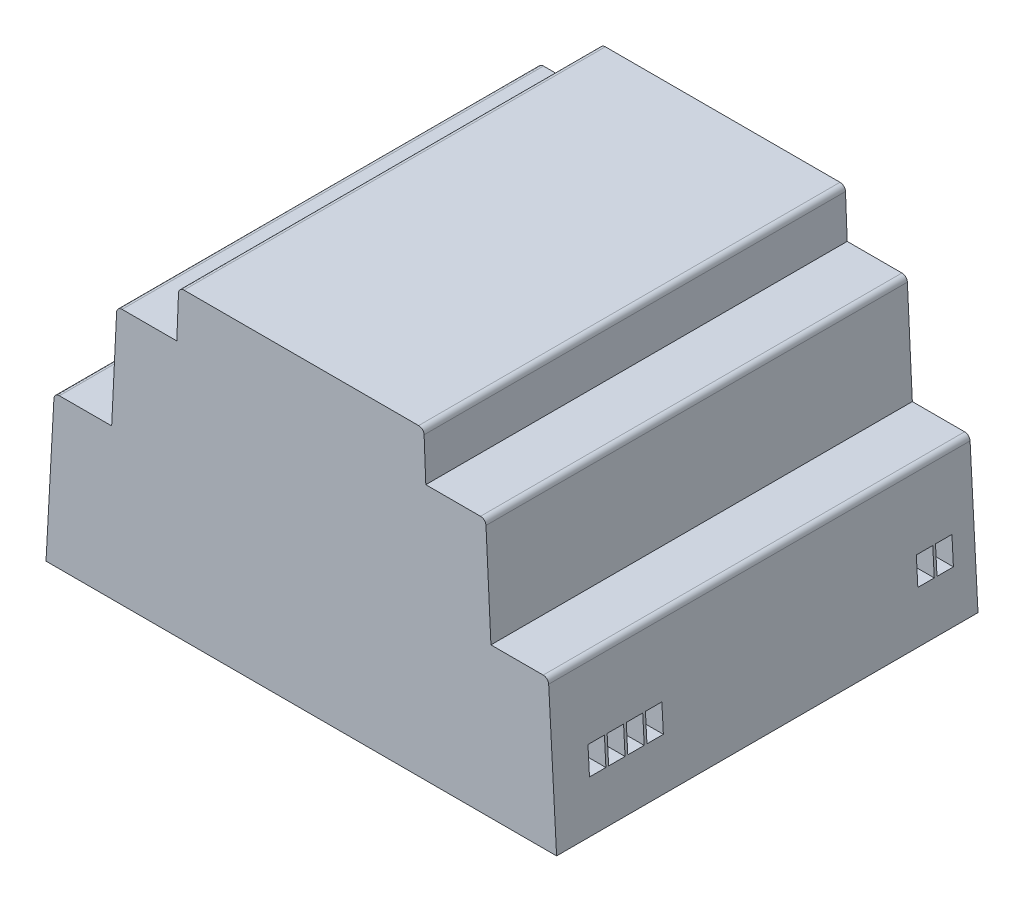
from build123d import *

# Parameters (mm, degrees)
BOSS_EXTRUDE1_DEPTH       = 77
FILLET1_R                 = 1
SKETCH2_W                 = 3
SKETCH2_H                 = 5
CUT_EXTRUDE1_DEPTH        = 10
LPATTERN1_COUNT           = 2
LPATTERN1_PITCH           = 3.5
LPATTERN2_COUNT           = 2
LPATTERN2_PITCH           = 60
LPATTERN2_COPY_1_SKETCH_W = 3
LPATTERN2_COPY_1_SKETCH_H = 5
LPATTERN2_COPY_1_DEPTH    = 10
LPATTERN4_COUNT           = 2
LPATTERN4_PITCH           = 53
LPATTERN4_COPY_1_SKETCH_W = 3
LPATTERN4_COPY_1_SKETCH_H = 5
LPATTERN4_COPY_1_DEPTH    = 10


with BuildPart() as part:
    # Sketch1 → Boss-Extrude1 (new body)
    with BuildSketch(Plane.XY):
        Polygon((-46.65, 0), (46.65, 0), (45.15, 27.4), (34.65, 27.4), (33.7, 46.8), (22.75, 46.8), (22.4, 55.5), (-22.4, 55.5), (-22.75, 46.8), (-33.7, 46.8), (-34.65, 27.4), (-45.15, 27.4), align=None)
    extrude(amount=BOSS_EXTRUDE1_DEPTH)

    # Fillet1
    fillet1_edges = [part.edges().sort_by_distance(p)[0] for p in [
        (-45.15, 27.4, 38.5),
        (-33.7, 46.8, 38.5),
        (-22.4, 55.5, 38.5),
        (22.4, 55.5, 38.5),
        (33.7, 46.8, 38.5),
        (45.15, 27.4, 38.5),
    ]]
    fillet(fillet1_edges, radius=FILLET1_R)

    # Sketch2 → Cut-Extrude1 (cut)
    with BuildSketch(Plane(origin=(46.65, 0, 0), x_dir=(0, 0, -1), z_dir=(1, 0, 0))):
        with Locations((-5.5, 11.5)):
            Rectangle(SKETCH2_W, SKETCH2_H)
    cut_extrude1 = extrude(amount=-CUT_EXTRUDE1_DEPTH, mode=Mode.SUBTRACT)

    # LPattern1: Cut-Extrude1 ×2
    with Locations(*[(0, 0, i * LPATTERN1_PITCH) for i in range(1, LPATTERN1_COUNT)]):
        add(cut_extrude1, mode=Mode.SUBTRACT)

    # LPattern2: Cut-Extrude1 ×2
    with Locations(*[(0, 0, i * LPATTERN2_PITCH) for i in range(1, LPATTERN2_COUNT)]):
        add(cut_extrude1, mode=Mode.SUBTRACT)

    # LPattern2 copy 1 sketch → LPattern2 copy 1 (cut)
    with BuildSketch(Plane(origin=(46.65, 0, 63.5), x_dir=(0, 0, -1), z_dir=(1, 0, 0))):
        with Locations((-5.5, 11.5)):
            Rectangle(LPATTERN2_COPY_1_SKETCH_W, LPATTERN2_COPY_1_SKETCH_H)
    extrude(amount=-LPATTERN2_COPY_1_DEPTH, mode=Mode.SUBTRACT)

    # LPattern4: Cut-Extrude1 ×2
    with Locations(*[(0, 0, i * LPATTERN4_PITCH) for i in range(1, LPATTERN4_COUNT)]):
        add(cut_extrude1, mode=Mode.SUBTRACT)

    # LPattern4 copy 1 sketch → LPattern4 copy 1 (cut)
    with BuildSketch(Plane(origin=(46.65, 0, 56.5), x_dir=(0, 0, -1), z_dir=(1, 0, 0))):
        with Locations((-5.5, 11.5)):
            Rectangle(LPATTERN4_COPY_1_SKETCH_W, LPATTERN4_COPY_1_SKETCH_H)
    extrude(amount=-LPATTERN4_COPY_1_DEPTH, mode=Mode.SUBTRACT)


solid = part.part
